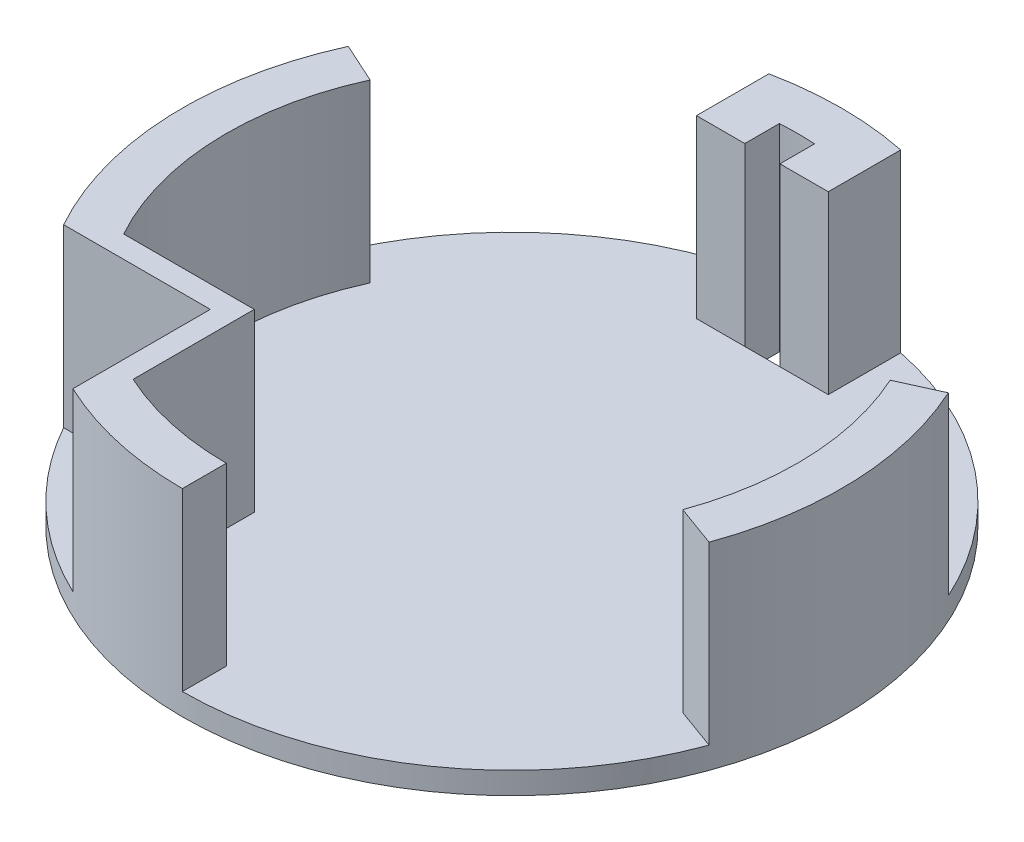
from build123d import *

# Parameters (mm, degrees)
SKETCH1_R           = 75
BOSS_EXTRUDE1_DEPTH = 5
CUT_EXTRUDE1_DEPTH  = 10
BOSS_EXTRUDE3_DEPTH = 40


with BuildPart() as part:
    # Sketch1 → Boss-Extrude1 (new body)
    with BuildSketch(Plane(origin=(0, 0, 0), x_dir=(1, 0, 0), z_dir=(0, 1, 0))):
        with Locations((-5.935816789, 0)):
            Circle(SKETCH1_R)
    extrude(amount=BOSS_EXTRUDE1_DEPTH)

    # Sketch2 → Cut-Extrude1 (cut)
    with BuildSketch(Plane(origin=(0, 5, 0), x_dir=(1, 0, 0), z_dir=(0, 1, 0))):
        with BuildLine():
            Line((-1.948906052, 56.999998596), (-1.948906052, 64.87761203))
            ThreePointArc((-1.948906052, 64.87761203), (-5.948930907, 64.999998677), (-9.948906052, 64.875997985))
            Line((-9.948906052, 64.875997985), (-9.948906052, 56.999998596))
            Line((-9.948906052, 56.999998596), (-1.948906052, 56.999998596))
        make_face()
    extrude(amount=-CUT_EXTRUDE1_DEPTH, mode=Mode.SUBTRACT)

    # Sketch2_5 → Boss-Extrude3 (add)
    with BuildSketch(Plane(origin=(0, 5, 0), x_dir=(1, 0, 0), z_dir=(0, 1, 0))):
        with BuildLine():
            Line((55.150755737, -22.213299101), (64.548689972, -25.630729732))
            ThreePointArc((64.548689972, -25.630729732), (69.007362578, 2.918881011), (62.34166902, 31.035220823))
            Line((62.34166902, 31.035220823), (53.238004246, 26.89719138))
            ThreePointArc((53.238004246, 26.89719138), (59.014938662, 2.529696877), (55.150755737, -22.213299101))
        make_face()
        with BuildLine():
            Line((-5.935816789, -75), (-5.935816789, -65))
            ThreePointArc((-5.935816789, -65), (-19.824804959, -63.49878745), (-33.072244718, -59.064492542))
            Line((-33.072244718, -59.064492542), (-33.072244718, -31.5))
            Line((-33.072244718, -31.5), (-62.793094248, -31.5))
            ThreePointArc((-62.793094248, -31.5), (-70.884734753, -2.576442379), (-65.109637824, 26.89719138))
            Line((-65.109637824, 26.89719138), (-74.213302599, 31.035220823))
            ThreePointArc((-74.213302599, 31.035220823), (-80.873336418, -3.06074368), (-71.454897979, -36.5))
            Line((-71.454897979, -36.5), (-38.072244718, -36.5))
            Line((-38.072244718, -36.5), (-38.072244718, -67.766141988))
            ThreePointArc((-38.072244718, -67.766141988), (-22.406083194, -73.169189722), (-5.935816789, -75))
        make_face()
        with BuildLine():
            ThreePointArc((-9.948906052, 64.875997985), (-5.948930907, 64.999998677), (-1.948906052, 64.87761203))
            Line((-1.948906052, 64.87761203), (-1.948906052, 56.999998596))
            Line((-1.948906052, 56.999998596), (9.051093948, 56.999998596))
            Line((9.051093948, 56.999998596), (9.051093948, 73.487362904))
            ThreePointArc((9.051093948, 73.487362904), (-5.949175962, 74.99999881), (-20.948906052, 73.482019235))
            Line((-20.948906052, 73.482019235), (-20.948906052, 56.999998596))
            Line((-20.948906052, 56.999998596), (-9.948906052, 56.999998596))
            Line((-9.948906052, 56.999998596), (-9.948906052, 64.875997985))
        make_face()
    extrude(amount=BOSS_EXTRUDE3_DEPTH)


solid = part.part
